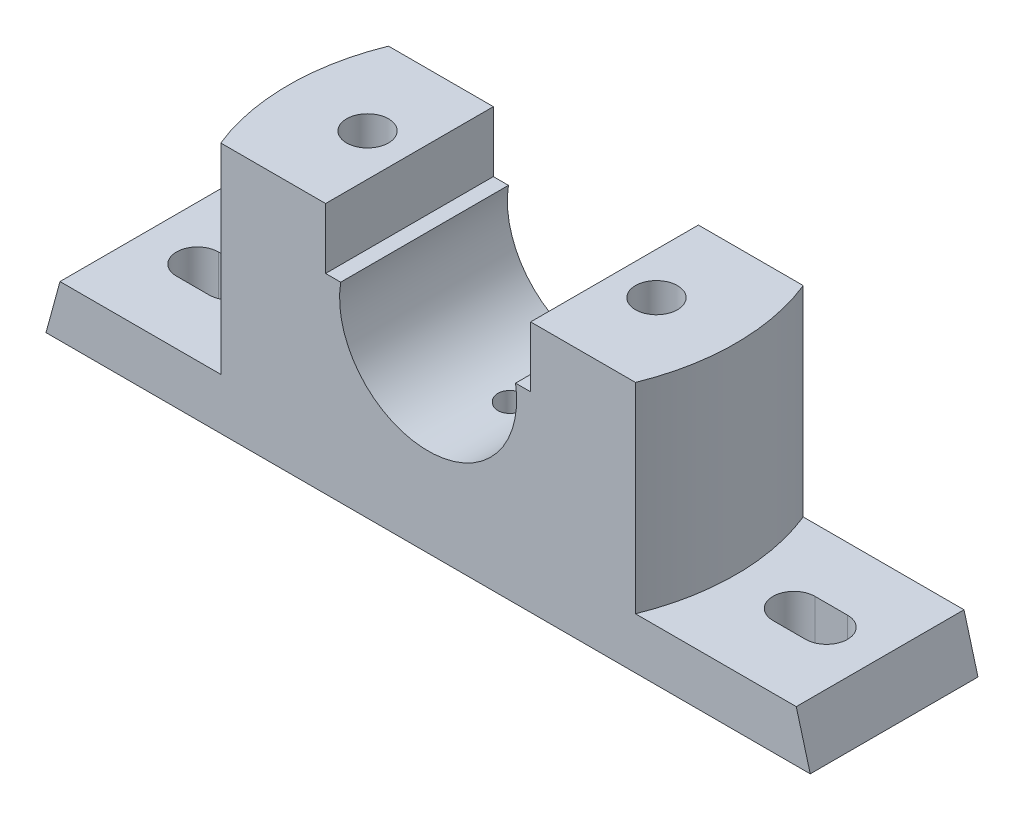
from build123d import *

# Parameters (mm, degrees)
BOSS_EXTRUDE1_DEPTH       = 18
F_1_0MM_DOWEL_HOLE3_D     = 9
SKETCH12_W                = 20
SKETCH12_H                = 20
CUT_EXTRUDE2_DEPTH        = 6
CUT_EXTRUDE3_DEPTH        = 12
CUT_EXTRUDE4_DEPTH        = 43
F_1_0MM_DOWEL_HOLE4_D     = 6
F_1_0MM_DOWEL_HOLE4_DEPTH = 6
F_1_0MM_DOWEL_HOLE4_TIP   = 1.802581857


with BuildPart() as part:
    # Sketch2 → Boss-Extrude1 (new body, symmetric)
    with BuildSketch(Plane.XY):
        with BuildLine():
            Line((18.761663039, 3), (22, 3))
            Line((22, 3), (22, 16))
            Line((22, 16), (50, 16))
            Line((50, 16), (50, -27))
            Line((50, -27), (79, -27))
            Line((79, -27), (82, -38))
            Line((82, -38), (-82, -38))
            Line((-82, -38), (-79, -27))
            Line((-79, -27), (-50, -27))
            Line((-50, -27), (-50, 16))
            Line((-50, 16), (-22, 16))
            Line((-22, 16), (-22, 3))
            Line((-22, 3), (-18.761663039, 3))
            ThreePointArc((-18.761663039, 3), (0, -19), (18.761663039, 3))
        make_face()
    extrude(amount=BOSS_EXTRUDE1_DEPTH, both=True)

    # Ø1.0mm Dowel Hole3 (through all)
    with Locations(Plane(origin=(0, 16, 0), x_dir=(1, 0, 0), z_dir=(0, 1, 0))):
        with Locations((-31, 0), (31, 0)):
            Hole(F_1_0MM_DOWEL_HOLE3_D / 2)

    # Sketch12 → Cut-Extrude2 (cut)
    with BuildSketch(Plane.XZ.offset(38)):
        with Locations((-31, 0)):
            Rectangle(SKETCH12_W, SKETCH12_H)
    cut_extrude2 = extrude(amount=-CUT_EXTRUDE2_DEPTH, mode=Mode.SUBTRACT)

    # Sketch13 → Cut-Extrude3 (cut, through all)
    with BuildSketch(Plane(origin=(0, -27, 0), x_dir=(1, 0, 0), z_dir=(0, 1, 0))):
        with BuildLine():
            Line((-67.5, 4.5), (-60.5, 4.5))
            ThreePointArc((-60.5, 4.5), (-56, 0), (-60.5, -4.5))
            Line((-60.5, -4.5), (-67.5, -4.5))
            ThreePointArc((-67.5, -4.5), (-72, 0), (-67.5, 4.5))
        make_face()
        with BuildLine():
            Line((60.5, 4.5), (67.5, 4.5))
            ThreePointArc((67.5, 4.5), (72, 0), (67.5, -4.5))
            Line((67.5, -4.5), (60.5, -4.5))
            ThreePointArc((60.5, -4.5), (56, 0), (60.5, 4.5))
        make_face()
    extrude(amount=-CUT_EXTRUDE3_DEPTH, mode=Mode.SUBTRACT)

    # Mirror1: Cut-Extrude2 across plane
    add(cut_extrude2.mirror(Plane(origin=(0, 0, 0), x_dir=(0, 0, 1), z_dir=(1, 0, 0))), mode=Mode.SUBTRACT)

    # Sketch17 → Cut-Extrude4 (cut)
    with BuildSketch(Plane(origin=(0, 16, 0), x_dir=(1, 0, 0), z_dir=(0, 1, 0))):
        with BuildLine():
            Line((-44.497190923, 18), (-50, 18))
            Line((-50, 18), (-50, -18))
            Line((-50, -18), (-44.497190923, -18))
            ThreePointArc((-44.497190923, -18), (-48, 0), (-44.497190923, 18))
        make_face()
    cut_extrude4 = extrude(amount=-CUT_EXTRUDE4_DEPTH, mode=Mode.SUBTRACT)

    # Mirror3: Cut-Extrude4 across plane
    add(cut_extrude4.mirror(Plane(origin=(0, 0, 0), x_dir=(0, 0, 1), z_dir=(1, 0, 0))), mode=Mode.SUBTRACT)

    # Ø1.0mm Dowel Hole4
    with Locations(Plane(origin=(0, -19, 0), x_dir=(1, 0, 0), z_dir=(0, 1, 0))):
        with Locations((0, 0)):
            Hole(F_1_0MM_DOWEL_HOLE4_D / 2, depth=F_1_0MM_DOWEL_HOLE4_DEPTH)
            with Locations((0, 0, -(F_1_0MM_DOWEL_HOLE4_DEPTH + F_1_0MM_DOWEL_HOLE4_TIP / 2))):  # 118° drill point
                Cone(0, F_1_0MM_DOWEL_HOLE4_D / 2, F_1_0MM_DOWEL_HOLE4_TIP, mode=Mode.SUBTRACT)


solid = part.part
